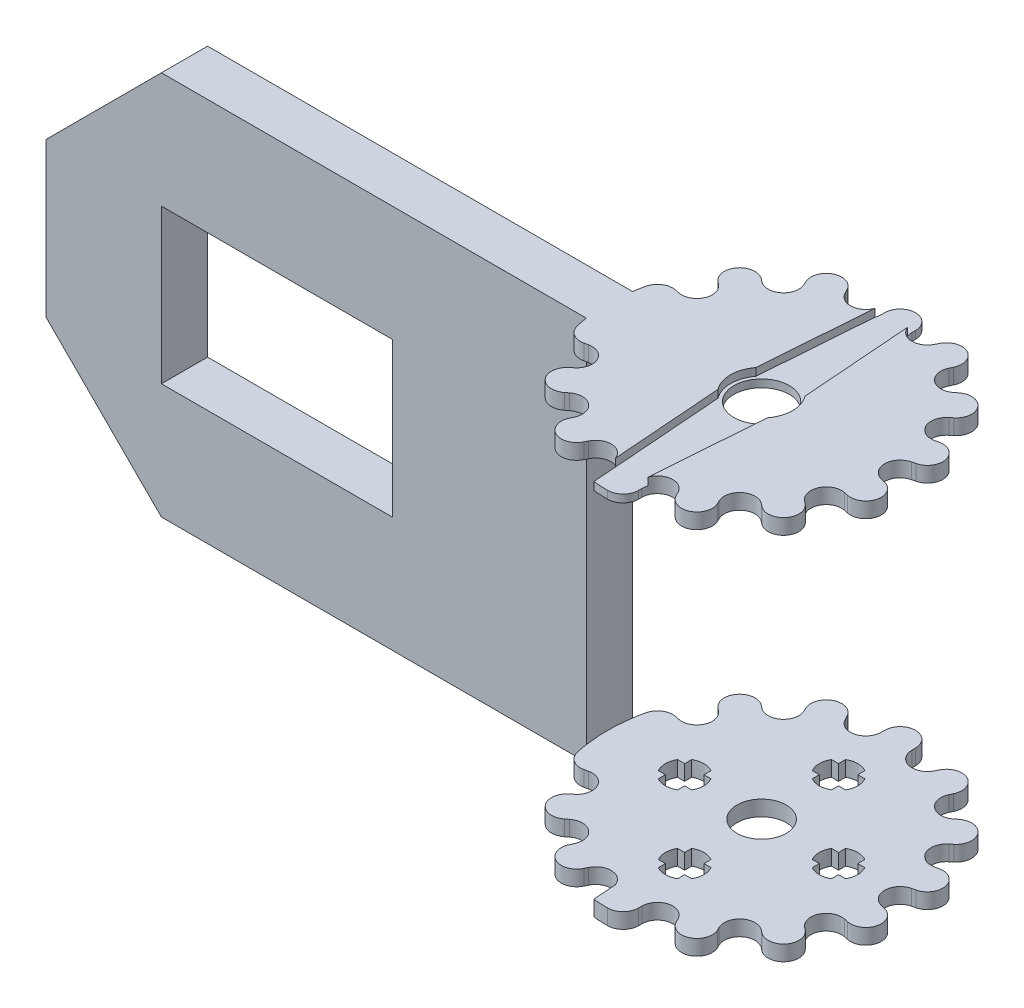
from build123d import *

# Parameters (mm, degrees)
SALIENTE_EXTRUIR1_DEPTH = 50
SALIENTE_EXTRUIR2_DEPTH = 2
CORTAR_EXTRUIR2_START   = -2
CORTAR_EXTRUIR2_DEPTH   = 2
CORTAR_EXTRUIR3_DEPTH   = 1
CROQUIS4_R              = 3.6
CORTAR_EXTRUIR4_DEPTH   = 11
CORTAR_EXTRUIR5_DEPTH   = 10
CORTAR_EXTRUIR6_REACH   = 106.881
CROQUIS6_R              = 3.2
CORTAR_EXTRUIR7_REACH   = 112.454
CORTAR_EXTRUIR8_REACH   = 106.881
CORTAR_EXTRUIR9_DEPTH   = 105.88088481701546
CORTAR_EXTRUIR10_REACH  = 106.881


with BuildPart() as part:
    # Croquis1 → Saliente-Extruir1 (new body)
    with BuildSketch(Plane(origin=(0, 0, 0), x_dir=(1, 0, 0), z_dir=(0, 1, 0))):
        with BuildLine():
            Line((-80, -20.000000000000014), (2.45e-15, -20))
            ThreePointArc((2.89e-15, -20), (-7.633172963984118, -18.486066928957655), (-14.110734629252049, -14.17346705019019))
            ThreePointArc((-14.110734629252049, -14.17346705019019), (-14.197060684438634, -14.086996412378578), (-14.282856857085687, -14.000000000000014))
            ThreePointArc((-14.28285685708569, -14.00000000000002), (-19.031883923290607, -6.147145217935962), (-19.773719933285207, 2.999999999999991))
            Line((-19.773719933285193, 2.9999999999999893), (-90, 2.9999999999999893))
            Line((-90, 2.9999999999999893), (-90, -14.000000000000014))
            Line((-90, -14.000000000000014), (-90, -20.000000000000004))
            Line((-90, -20.000000000000004), (-80, -20.000000000000014))
        make_face()
    extrude(amount=SALIENTE_EXTRUIR1_DEPTH)

    # Croquis1_3 → Saliente-Extruir2 (add)
    with BuildSketch(Plane(origin=(0, 0, 0), x_dir=(1, 0, 0), z_dir=(0, 1, 0))):
        with BuildLine():
            ThreePointArc((-14.110734629252049, -14.17346705019019), (-7.633172963984118, -18.486066928957655), (2.89e-15, -20))
            ThreePointArc((2.66e-15, -19.999999999999993), (15.165750888103084, 13.038404810405323), (-19.773719933285207, 2.999999999999991))
            ThreePointArc((-19.773719933285207, 2.999999999999991), (-19.031883923290607, -6.147145217935962), (-14.28285685708569, -14.00000000000002))
            ThreePointArc((-14.282856857085687, -14.000000000000014), (-14.197060684438634, -14.086996412378578), (-14.110734629252049, -14.17346705019019))
        make_face()
    saliente_extruir2 = extrude(amount=SALIENTE_EXTRUIR2_DEPTH)

    # Simetría1: Saliente-Extruir2 across plane
    add(saliente_extruir2.mirror(Plane.ZX.offset(25)))

    # Croquis2 → Cortar-Extruir2 (cut)
    with BuildSketch(Plane(origin=(0, 50, 0), x_dir=(1, 0, 0), z_dir=(0, 1, 0)).offset(CORTAR_EXTRUIR2_START)):
        with BuildLine():
            ThreePointArc((2.3069065e-09, 20.000000000001528), (1.414213563188283, 19.41421356155916), (1.999999999999393, 18.000000000002093))
            Line((1.9999999999984908, 18.000000000002093), (2.005376811216343, 17.548702419276584))
            ThreePointArc((2.005376811216343, 17.548702419276584), (3.560334943301406, 15.598846594914638), (5.807314547017347, 16.680934941039958))
            Line((5.8073145470159115, 16.680934941040647), (6.007969568312868, 17.085207100481572))
            ThreePointArc((6.007969568312868, 17.085207100481572), (7.14934781279133, 18.10520580438261), (8.677672171860614, 18.019378615194125))
            ThreePointArc((8.677672171860614, 18.019378615194125), (4.450417267860161, 19.498558565748695), (2.30690911e-09, 19.999999999999996))
        make_face()
        with BuildLine():
            Line((-2.0053768112160335, 17.548702419273013), (-1.9999999999985785, 18.000000000002093))
            ThreePointArc((-1.9999999999994804, 18.000000000002093), (-1.4142135615571099, 19.41421356319042), (2.3069065e-09, 20.000000000001528))
            ThreePointArc((2.30690911e-09, 19.999999999999996), (-4.4504186606100244, 19.49855824786269), (-8.677674750206416, 18.01937737352848))
            ThreePointArc((-8.677674750205977, 18.01937737352757), (-7.149349163368259, 18.10520627696775), (-6.007969568312289, 17.085207100478637))
            Line((-6.007969568312291, 17.085207100478637), (-5.807314547016526, 16.680934941041006))
            ThreePointArc((-5.807314547016527, 16.680934941041006), (-3.5603349433019162, 15.598846594912995), (-2.005376811214484, 17.548702419273013))
        make_face()
        with BuildLine():
            ThreePointArc((15.636631733311763, 12.469793423982079), (12.469796211121498, 15.636629510642607), (8.677672171860614, 18.019378615194125))
            ThreePointArc((8.677672171860614, 18.019378615194125), (9.697673486251905, 16.877999113572148), (9.611845039919906, 15.349672144012613))
            Line((9.611845039919904, 15.349672144012613), (9.420878697655885, 14.94073416266352))
            ThreePointArc((9.420878697655885, 14.94073416266352), (9.97583682974195, 12.509303719494845), (12.46979603717416, 12.50930371949271))
            Line((12.469796037173232, 12.509303719493872), (12.8259870807093, 12.786479398396812))
            ThreePointArc((12.8259870807093, 12.786479398396812), (14.296897297324762, 13.210240666131124), (15.636631733311763, 12.469793423982079))
        make_face()
        with BuildLine():
            ThreePointArc((-9.611845039919325, 15.349672144009677), (-9.697673958839399, 16.877997762991708), (-8.677674750205977, 18.01937737352757))
            ThreePointArc((-8.677674750206416, 18.01937737352848), (-12.469795992641606, 15.636629684874546), (-15.636629600577583, 12.469796098346656))
            ThreePointArc((-15.636629600575713, 12.469796098345164), (-14.2968955977551, 13.210240857621947), (-12.825987080706847, 12.786479398391526))
            Line((-12.825987080706847, 12.786479398391524), (-12.469796037173134, 12.509303719491054))
            ThreePointArc((-12.469796037173134, 12.509303719491054), (-9.975836829740919, 12.509303719490351), (-9.4208786976521, 14.94073416265841))
            Line((-9.420878697654013, 14.940734162657488), (-9.611845039919327, 15.349672144009675))
        make_face()
        with BuildLine():
            ThreePointArc((19.49855758048308, 4.450421584589991), (18.019377436628034, 8.67767461917877), (15.636631733311763, 12.469793423982079))
            ThreePointArc((15.636631733311763, 12.469793423982079), (16.06039091709508, 10.99888582056299), (15.319946288142408, 9.659153468526982))
            Line((15.319946288142408, 9.659153468526982), (14.9704600185304, 9.373570269055707))
            ThreePointArc((14.9704600185304, 9.373570269055707), (14.41550188644297, 6.9421398258872875), (16.662481490157155, 5.860051479758109))
            Line((16.662481490156836, 5.86005147975951), (17.103660551363593, 5.955232635580833))
            ThreePointArc((17.103660551363593, 5.955232635580833), (18.612765310610328, 5.698826002448645), (19.49855758048308, 4.450421584589991))
        make_face()
        with BuildLine():
            ThreePointArc((-15.319946288139981, 9.659153468521279), (-16.060391108588973, 10.998887520124836), (-15.636629600575713, 12.469796098345164))
            ThreePointArc((-15.636629600577583, 12.469796098346656), (-18.019377321434987, 8.677674858379707), (-19.49855822349195, 4.450418767385283))
            ThreePointArc((-19.498558223487706, 4.450418767384313), (-18.612766533973286, 5.698825233749674), (-17.103660551357997, 5.955232635574186))
            Line((-17.103660551357997, 5.955232635574187), (-16.662481490154693, 5.86005147975374))
            ThreePointArc((-16.662481490154693, 5.860051479753739), (-14.41550188643936, 6.942139825880531), (-14.97046001852426, 9.373570269049525))
            Line((-14.970460018525287, 9.373570269048237), (-15.319946288139981, 9.659153468521277))
        make_face()
        with BuildLine():
            ThreePointArc((19.49855761538362, -4.450421431680837), (19.999999999999968, 7.842075111e-08), (19.49855758048308, 4.450421584589991))
            ThreePointArc((19.49855758048308, 4.450421584589991), (19.242151610505502, 2.941313919884113), (17.993744287187894, 2.055520986856794))
            Line((17.993744287187894, 2.055520986856793), (17.55495813209263, 1.949855824366283))
            ThreePointArc((17.55495813209263, 1.9498558243662825), (16.000000000006338, 5.05523e-12), (17.55495813209016, -1.949855824358141))
            Line((17.554958132090672, -1.949855824355902), (17.993744287189656, -2.0555209868466817))
            ThreePointArc((17.993744287189656, -2.055520986846682), (19.242151568787918, -2.941313853477494), (19.498557615383618, -4.450421431680837))
        make_face()
        with BuildLine():
            ThreePointArc((15.636630550421227, -12.46979490728025), (18.01937705906936, -8.677675403187406), (19.49855761538362, -4.450421431680837))
            ThreePointArc((19.498557615383618, -4.450421431680837), (18.61276537700848, -5.698825960719235), (17.103660551364847, -5.955232635570574))
            Line((17.103660551364847, -5.9552326355705745), (16.66248149016167, -5.86005147975068))
            ThreePointArc((16.66248149016167, -5.86005147975068), (14.415501886446537, -6.942139825877181), (14.970460018531252, -9.373570269045903))
            Line((14.970460018532027, -9.373570269044931), (15.319946288146854, -9.659153468518342))
            ThreePointArc((15.319946288146854, -9.659153468518342), (16.060391023310608, -10.998886763199065), (15.636630550421227, -12.46979490728025))
        make_face()
        with BuildLine():
            ThreePointArc((8.677674713264576, -18.019377391318706), (12.469796572146292, -15.636629222734916), (15.636630550421227, -12.46979490728025))
            ThreePointArc((15.636630550421227, -12.46979490728025), (14.29689635468447, -13.210240772333371), (12.82598708071392, -12.786479398387957))
            Line((12.82598708071392, -12.786479398387957), (12.469796037179986, -12.50930371948769))
            ThreePointArc((12.469796037179986, -12.50930371948769), (9.97583682974798, -12.50930371948696), (9.420878697659111, -14.940734162654792))
            Line((9.420878697660456, -14.940734162654145), (9.61184503992609, -15.349672144006384))
            ThreePointArc((9.61184503992609, -15.349672144006384), (9.697673952073782, -16.877997782342636), (8.677674713264071, -18.019377391317658))
        make_face()
        with BuildLine():
            ThreePointArc((8.9e-16, -19.99999999999999), (4.450418641747394, -19.498558252167943), (8.677674713264576, -18.019377391318706))
            ThreePointArc((8.677674713264071, -18.019377391317658), (7.149349144020865, -18.105206270191893), (6.0079695683192975, -17.085207100475227))
            Line((6.007969568319298, -17.085207100475227), (5.807314547023248, -16.680934941037684))
            ThreePointArc((5.807314547023248, -16.680934941037684), (3.5603349433087352, -15.59884659490976), (2.005376811221468, -17.54870241926975))
            Line((2.0053768112229533, -17.54870241926975), (2.0000000000051923, -17.99999999999879))
            ThreePointArc((2.000000000005192, -17.99999999999879), (1.414213562376355, -19.414213562373153), (1.62e-15, -19.999999999997186))
        make_face()
    cortar_extruir2 = extrude(amount=CORTAR_EXTRUIR2_DEPTH, mode=Mode.SUBTRACT)

    # Simetría2: Cortar-Extruir2 across plane
    add(cortar_extruir2.mirror(Plane.ZX.offset(25)), mode=Mode.SUBTRACT)

    # Croquis3 → Cortar-Extruir3 (cut)
    with BuildSketch(Plane(origin=(0, 50, 0), x_dir=(1, 0, 0), z_dir=(0, 1, 0))):
        with BuildLine():
            Line((-1.8774496877167555, -20.18158458174188), (1.8774496877167555, -20.18158458174188))
            Line((1.8774496877167555, -20.18158458174188), (3.209356135005593, -2.450749419885596))
            ThreePointArc((3.209356135005593, -2.450749419885596), (4.038086120969608, 4.73e-15), (3.209356135005593, 2.450749419885596))
            Line((3.209356135005593, 2.450749419885596), (1.8774496877167555, 20.18158458174188))
            Line((1.8774496877167555, 20.18158458174188), (-1.8774496877167555, 20.18158458174188))
            Line((-1.8774496877167555, 20.18158458174188), (-3.209356135005594, 2.4507494198855952))
            ThreePointArc((-3.209356135005594, 2.4507494198855952), (-4.038086120969642, 5.22e-15), (-3.209356135005594, -2.4507494198855952))
            Line((-3.209356135005594, -2.4507494198855952), (-1.8774496877167555, -20.18158458174188))
        make_face()
    extrude(amount=-CORTAR_EXTRUIR3_DEPTH, mode=Mode.SUBTRACT)

    # Croquis4 → Cortar-Extruir4 (cut)
    with BuildSketch(Plane(origin=(0, 49, 0), x_dir=(1, 0, 0), z_dir=(0, 1, 0))):
        with Locations(Location((0, 0, 0), (0, 0, 270))):
            Circle(CROQUIS4_R)
    extrude(amount=-CORTAR_EXTRUIR4_DEPTH, mode=Mode.SUBTRACT)

    # Croquis5 → Cortar-Extruir5 (cut)
    with BuildSketch(Plane.XY.offset(20.000000000000096)):
        Polygon((2.082e-14, 3.993528726796321), (-28.15, 3.993528726796321), (-28.15, 46.00647127320368), (6.94e-15, 46.00647127320368), (2.082e-14, 25), align=None)
    extrude(amount=-CORTAR_EXTRUIR5_DEPTH, mode=Mode.SUBTRACT)

    # Croquis6 → Cortar-Extruir6 (cut, up to next)
    with BuildSketch(Plane.XZ, mode=Mode.PRIVATE) as cortar_extruir6_sk1:
        with Locations(Location((0, 0, 0), (0, 0, 270))):
            Circle(CROQUIS6_R)
    cortar_extruir6_tool1 = extrude(cortar_extruir6_sk1.sketch, amount=-CORTAR_EXTRUIR6_REACH, mode=Mode.PRIVATE) & part.part
    add(cortar_extruir6_tool1.solids().sort_by_distance((0, 0, 0))[0], mode=Mode.SUBTRACT)

    # Croquis7 → Cortar-Extruir7 (cut, up to next)
    with BuildSketch(Plane.XY.offset(20.000000000000096), mode=Mode.PRIVATE) as cortar_extruir7_sk1:
        Polygon((-44.99999999999998, 35), (-44.99999999999997, 15.000000000000002), (-74.99999999999997, 15.000000000000002), (-74.99999999999997, 35), align=None)
    cortar_extruir7_tool1 = extrude(cortar_extruir7_sk1.sketch, amount=-CORTAR_EXTRUIR7_REACH, mode=Mode.PRIVATE) & part.part
    # Croquis7 → Cortar-Extruir7 (cut, up to next)
    with BuildSketch(Plane.XY.offset(20.000000000000096), mode=Mode.PRIVATE) as cortar_extruir7_sk2:
        Polygon((-89.99999999999997, 50), (-89.99999999999997, 35), (-74.99999999999997, 50), align=None)
    cortar_extruir7_tool2 = extrude(cortar_extruir7_sk2.sketch, amount=-CORTAR_EXTRUIR7_REACH, mode=Mode.PRIVATE) & part.part
    # Croquis7 → Cortar-Extruir7 (cut, up to next)
    with BuildSketch(Plane.XY.offset(20.000000000000096), mode=Mode.PRIVATE) as cortar_extruir7_sk3:
        Polygon((-89.99999999999997, 0), (-74.99999999999997, 0), (-89.99999999999997, 14.999999999999996), align=None)
    cortar_extruir7_tool3 = extrude(cortar_extruir7_sk3.sketch, amount=-CORTAR_EXTRUIR7_REACH, mode=Mode.PRIVATE) & part.part
    add(cortar_extruir7_tool1.solids().sort_by_distance((-60, 25, 20))[0], mode=Mode.SUBTRACT)
    add(cortar_extruir7_tool2.solids().sort_by_distance((-85, 45, 20))[0], mode=Mode.SUBTRACT)
    add(cortar_extruir7_tool3.solids().sort_by_distance((-85, 5, 20))[0], mode=Mode.SUBTRACT)

    # Croquis9 → Cortar-Extruir8 (cut, up to next)
    with BuildSketch(Plane(origin=(0, 50, 0), x_dir=(1, 0, 0), z_dir=(0, 1, 0)), mode=Mode.PRIVATE) as cortar_extruir8_sk1:
        with BuildLine():
            Line((-90, -2.9999999999999827), (-19.773719933279956, -2.9999999999999827))
            ThreePointArc((-19.773719933279956, -2.9999999999999827), (-13.038404810402403, -15.165750888100995), (2.45e-15, -19.999999999997186))
            Line((2.45e-15, -19.999999999997186), (-90, -20.000000000000004))
            Line((-90, -20.000000000000004), (-90, -2.9999999999999827))
        make_face()
    cortar_extruir8_tool1 = extrude(cortar_extruir8_sk1.sketch, amount=-CORTAR_EXTRUIR8_REACH, mode=Mode.PRIVATE) & part.part
    add(cortar_extruir8_tool1.solids().sort_by_distance((-52.350306, 50, 11.773008))[0], mode=Mode.SUBTRACT)

    # Croquis10 → Cortar-Extruir9 (cut, through all)
    with BuildSketch(Plane(origin=(0, 50, 0), x_dir=(1, 0, 0), z_dir=(0, 1, 0))):
        with BuildLine():
            ThreePointArc((-6.007969568306386, -17.085207100478197), (-7.149349189273373, -18.10520628603392), (-8.677674799665937, -18.019377349705465))
            ThreePointArc((-8.67767479966773, -18.019377349709174), (-5.371583577987183, -19.265152214937178), (-1.8978694831081173, -19.909748652986238))
            Line((-1.89786948310784, -19.909748652983414), (-2.1267711773974476, -16.862523963906963))
            ThreePointArc((-2.126771177397467, -16.862523963906966), (-3.9068215731276674, -15.551132178946482), (-5.807314547009169, -16.68093494103734))
            Line((-5.80731454700917, -16.68093494103734), (-6.007969568306386, -17.085207100478197))
        make_face()
        with BuildLine():
            ThreePointArc((-12.825987080702907, -12.786479398393311), (-14.296895646708647, -13.210240852107335), (-15.636629662006829, -12.469796021309053))
            ThreePointArc((-15.636629662010613, -12.469796021312069), (-12.469796052619348, -15.63662963704389), (-8.67767479966773, -18.019377349709174))
            ThreePointArc((-8.677674799665937, -18.019377349705465), (-9.697673967899924, -16.877997737080186), (-9.611845039913176, -15.349672144009356))
            Line((-9.611845039913176, -15.349672144009356), (-9.420878697649403, -14.940734162660092))
            ThreePointArc((-9.420878697649403, -14.940734162660092), (-9.975836829734991, -12.509303719492031), (-12.46979603716649, -12.50930371949057))
            Line((-12.46979603716649, -12.50930371949057), (-12.825987080702907, -12.786479398393311))
        make_face()
        with BuildLine():
            Line((-16.662481490150096, -5.860051479756206), (-17.103660551356427, -5.955232635577446))
            ThreePointArc((-17.103660551356427, -5.955232635577447), (-18.61276657229867, -5.698825209670835), (-19.498558243631162, -4.450418679127929))
            ThreePointArc((-19.498558243635866, -4.450418679128998), (-18.01937736244933, -8.677674773212527), (-15.636629662010613, -12.469796021312069))
            ThreePointArc((-15.636629662006829, -12.469796021309053), (-16.060391103068206, -10.998887471169233), (-15.319946288135844, -9.659153468523698))
            Line((-15.319946288135844, -9.659153468523698), (-14.970460018523982, -9.373570269052161))
            ThreePointArc((-14.970460018523982, -9.373570269052161), (-14.415501886436111, -6.942139825884446), (-16.662481490150096, -5.860051479756206))
        make_face()
    extrude(amount=-CORTAR_EXTRUIR9_DEPTH, mode=Mode.SUBTRACT)

    # Croquis11 → Cortar-Extruir10 (cut, up to next)
    with BuildSketch(Plane.XZ, mode=Mode.PRIVATE) as cortar_extruir10_sk1:
        with BuildLine():
            ThreePointArc((-1.2499999999999751, 12.165063509461074), (-0.6470476127562755, 12.414814565722645), (2.776e-14, 12.499999999999966))
            ThreePointArc((2.776e-14, 12.499999999999966), (0.6470476127563011, 12.414814565722669), (1.2500000000000002, 12.165063509461097))
            Line((1.2500000000000002, 12.165063509461097), (1.2500000000000002, 11.25))
            Line((1.2500000000000002, 11.25), (2.1650635094610977, 11.25))
            ThreePointArc((2.1650635094610977, 11.25), (2.414814565722672, 10.647047612756301), (2.499999999999995, 10.000000000000007))
            ThreePointArc((2.499999999999995, 10.000000000000007), (2.414814565722682, 9.352952387243702), (2.165063509461126, 8.749999999999995))
            Line((2.165063509461126, 8.749999999999995), (1.2500000000000289, 8.749999999999998))
            Line((1.2500000000000289, 8.749999999999998), (1.250000000000027, 7.8349364905389))
            ThreePointArc((1.250000000000027, 7.8349364905389), (0.6470476127563292, 7.585185434277321), (2.602e-14, 7.500000000000002))
            ThreePointArc((2.602e-14, 7.500000000000002), (-0.6470476127562762, 7.585185434277323), (-1.2499999999999811, 7.834936490538881))
            Line((-1.2499999999999811, 7.834936490538881), (-1.2499999999999747, 8.749999999999979))
            Line((-1.2499999999999747, 8.749999999999979), (-2.165063509461072, 8.749999999999986))
            ThreePointArc((-2.165063509461072, 8.749999999999986), (-2.4148145657226516, 9.352952387243683), (-2.4999999999999662, 9.999999999999986))
            ThreePointArc((-2.4999999999999662, 9.999999999999986), (-2.414814565722627, 10.64704761275628), (-2.165063509461081, 11.249999999999988))
            Line((-2.165063509461081, 11.249999999999988), (-1.2499999999999838, 11.249999999999977))
            Line((-1.2499999999999838, 11.249999999999977), (-1.2499999999999751, 12.165063509461074))
        make_face()
    cortar_extruir10_tool1 = extrude(cortar_extruir10_sk1.sketch, amount=-CORTAR_EXTRUIR10_REACH, mode=Mode.PRIVATE) & part.part
    # Croquis11 → Cortar-Extruir10 (cut, up to next)
    with BuildSketch(Plane.XZ, mode=Mode.PRIVATE) as cortar_extruir10_sk2:
        with BuildLine():
            ThreePointArc((-11.249999999999678, 2.1650635094609187), (-10.647047612755992, 2.4148145657224864), (-9.999999999999702, 2.4999999999998157))
            ThreePointArc((-9.999999999999702, 2.4999999999998157), (-9.352952387243413, 2.4148145657224878), (-8.749999999999725, 2.165063509460919))
            Line((-8.749999999999725, 2.165063509460919), (-8.749999999999721, 1.2499999999998361))
            Line((-8.749999999999721, 1.2499999999998361), (-7.834936490538629, 1.2499999999998221))
            ThreePointArc((-7.834936490538629, 1.2499999999998221), (-7.585185434277063, 0.6470476127561359), (-7.499999999999734, -1.5263e-13))
            ThreePointArc((-7.499999999999734, -1.5263e-13), (-7.585185434277062, -0.6470476127564422), (-7.834936490538631, -1.2500000000001288))
            Line((-7.834936490538631, -1.2500000000001288), (-8.749999999999714, -1.250000000000132))
            Line((-8.749999999999714, -1.250000000000132), (-8.749999999999728, -2.1650635094612243))
            ThreePointArc((-8.749999999999728, -2.1650635094612243), (-9.352952387243413, -2.4148145657227906), (-9.999999999999702, -2.5000000000001203))
            ThreePointArc((-9.999999999999702, -2.5000000000001203), (-10.647047612755992, -2.4148145657227937), (-11.24999999999968, -2.1650635094612256))
            Line((-11.24999999999968, -2.1650635094612256), (-11.249999999999684, -1.250000000000134))
            Line((-11.249999999999684, -1.250000000000134), (-12.165063509460776, -1.250000000000134))
            ThreePointArc((-12.165063509460776, -1.250000000000134), (-12.414814565722324, -0.6470476127565288), (-12.499999999999597, -3.2704e-13))
            ThreePointArc((-12.499999999999597, -3.2704e-13), (-12.414814565722295, 0.6470476127560375), (-12.165063509460776, 1.2499999999998332))
            Line((-12.165063509460776, 1.2499999999998332), (-11.249999999999693, 1.2499999999998332))
            Line((-11.249999999999693, 1.2499999999998332), (-11.249999999999678, 2.1650635094609187))
        make_face()
    cortar_extruir10_tool2 = extrude(cortar_extruir10_sk2.sketch, amount=-CORTAR_EXTRUIR10_REACH, mode=Mode.PRIVATE) & part.part
    # Croquis11 → Cortar-Extruir10 (cut, up to next)
    with BuildSketch(Plane.XZ, mode=Mode.PRIVATE) as cortar_extruir10_sk3:
        with BuildLine():
            ThreePointArc((11.250000000000407, -2.16506350946084), (10.64704761275672, -2.414814565722407), (10.000000000000432, -2.499999999999737))
            ThreePointArc((10.000000000000432, -2.499999999999737), (9.352952387244141, -2.4148145657224096), (8.750000000000453, -2.1650635094608406))
            Line((8.750000000000453, -2.1650635094608406), (8.75000000000045, -1.2499999999997573))
            Line((8.75000000000045, -1.2499999999997573), (7.834936490539358, -1.2499999999997435))
            ThreePointArc((7.834936490539358, -1.2499999999997435), (7.585185434277791, -0.6470476127560576), (7.500000000000464, 2.3157e-13))
            ThreePointArc((7.500000000000464, 2.3157e-13), (7.58518543427779, 0.6470476127565208), (7.83493649053936, 1.2500000000002076))
            Line((7.83493649053936, 1.2500000000002076), (8.750000000000442, 1.2500000000002105))
            Line((8.750000000000442, 1.2500000000002105), (8.750000000000457, 2.1650635094613024))
            ThreePointArc((8.750000000000457, 2.1650635094613024), (9.352952387244143, 2.41481456572287), (10.000000000000432, 2.5000000000001985))
            ThreePointArc((10.000000000000432, 2.5000000000001985), (10.64704761275672, 2.4148145657228715), (11.250000000000409, 2.1650635094613038))
            Line((11.250000000000409, 2.1650635094613038), (11.250000000000412, 1.2500000000002203))
            Line((11.250000000000412, 1.2500000000002203), (12.165063509461506, 1.2500000000002072))
            ThreePointArc((12.165063509461506, 1.2500000000002072), (12.41481456572305, 0.6470476127566043), (12.500000000000325, 4.0536e-13))
            ThreePointArc((12.500000000000325, 4.0536e-13), (12.414814565723022, -0.647047612755955), (12.165063509461504, -1.249999999999746))
            Line((12.165063509461504, -1.249999999999746), (11.250000000000421, -1.2499999999997484))
            Line((11.250000000000421, -1.2499999999997484), (11.250000000000407, -2.16506350946084))
        make_face()
    cortar_extruir10_tool3 = extrude(cortar_extruir10_sk3.sketch, amount=-CORTAR_EXTRUIR10_REACH, mode=Mode.PRIVATE) & part.part
    # Croquis11 → Cortar-Extruir10 (cut, up to next)
    with BuildSketch(Plane.XZ, mode=Mode.PRIVATE) as cortar_extruir10_sk4:
        with BuildLine():
            ThreePointArc((-2.165063509460515, -11.250000000000004), (-2.4148145657220823, -10.647047612756317), (-2.4999999999994116, -10.000000000000028))
            ThreePointArc((-2.4999999999994116, -10.000000000000028), (-2.414814565722084, -9.352952387243738), (-2.1650635094605155, -8.75000000000005))
            Line((-2.1650635094605155, -8.75000000000005), (-1.249999999999432, -8.750000000000046))
            Line((-1.249999999999432, -8.750000000000046), (-1.2499999999994185, -7.834936490538954))
            ThreePointArc((-1.2499999999994185, -7.834936490538954), (-0.647047612755732, -7.585185434277387), (5.5676e-13, -7.5000000000000595))
            ThreePointArc((5.5676e-13, -7.5000000000000595), (0.6470476127568465, -7.585185434277387), (1.2500000000005327, -7.834936490538956))
            Line((1.2500000000005327, -7.834936490538956), (1.2500000000005358, -8.750000000000039))
            Line((1.2500000000005358, -8.750000000000039), (2.165063509461628, -8.750000000000053))
            ThreePointArc((2.165063509461628, -8.750000000000053), (2.414814565723195, -9.35295238724374), (2.5000000000005245, -10.000000000000027))
            ThreePointArc((2.5000000000005245, -10.000000000000027), (2.4148145657231974, -10.647047612756317), (2.1650635094616293, -11.250000000000005))
            Line((2.1650635094616293, -11.250000000000005), (1.2500000000005456, -11.250000000000009))
            Line((1.2500000000005456, -11.250000000000009), (1.250000000000533, -12.1650635094611))
            ThreePointArc((1.250000000000533, -12.1650635094611), (0.6470476127569302, -12.414814565722645), (7.3087e-13, -12.49999999999992))
            ThreePointArc((7.3087e-13, -12.49999999999992), (-0.647047612755629, -12.414814565722619), (-1.2499999999994202, -12.1650635094611))
            Line((-1.2499999999994202, -12.1650635094611), (-1.2499999999994231, -11.250000000000018))
            Line((-1.2499999999994231, -11.250000000000018), (-2.165063509460515, -11.250000000000004))
        make_face()
    cortar_extruir10_tool4 = extrude(cortar_extruir10_sk4.sketch, amount=-CORTAR_EXTRUIR10_REACH, mode=Mode.PRIVATE) & part.part
    add(cortar_extruir10_tool1.solids().sort_by_distance((0, 0, 10))[0], mode=Mode.SUBTRACT)
    add(cortar_extruir10_tool2.solids().sort_by_distance((-10, 0, 0))[0], mode=Mode.SUBTRACT)
    add(cortar_extruir10_tool3.solids().sort_by_distance((10, 0, 0))[0], mode=Mode.SUBTRACT)
    add(cortar_extruir10_tool4.solids().sort_by_distance((0, 0, -10))[0], mode=Mode.SUBTRACT)


solid = part.part
